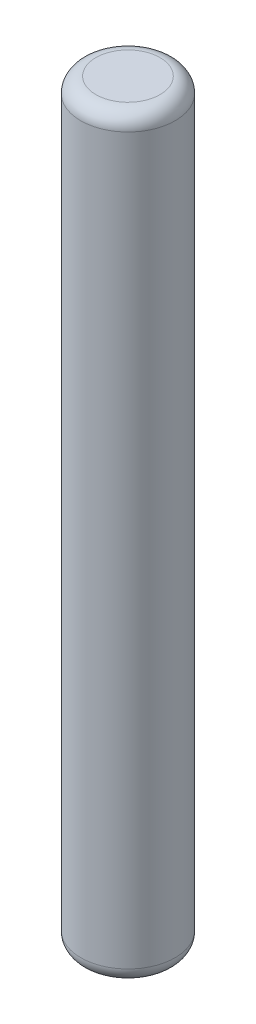
from build123d import *

# Parameters (mm, degrees)
SKETCH1_R      = 1.5875
EXTRUDE1_DEPTH = 25.4
FILLET1_R      = 0.508


with BuildPart() as part:
    # Sketch1 → Extrude1 (new body)
    with BuildSketch(Plane(origin=(0, 0, 0), x_dir=(1, 0, 0), z_dir=(0, 1, 0))):
        with Locations(Location((0, 0, 0), (0, 0, 270))):  # turned: the seam where the file's is
            Circle(SKETCH1_R)
    extrude(amount=EXTRUDE1_DEPTH)

    # Fillet1
    fillet1_edges = [part.edges().sort_by_distance(p)[0] for p in [
        (0, 0, -1.5875),
        (0, 25.4, -1.5875),
    ]]
    fillet(fillet1_edges, radius=FILLET1_R)


solid = part.part
